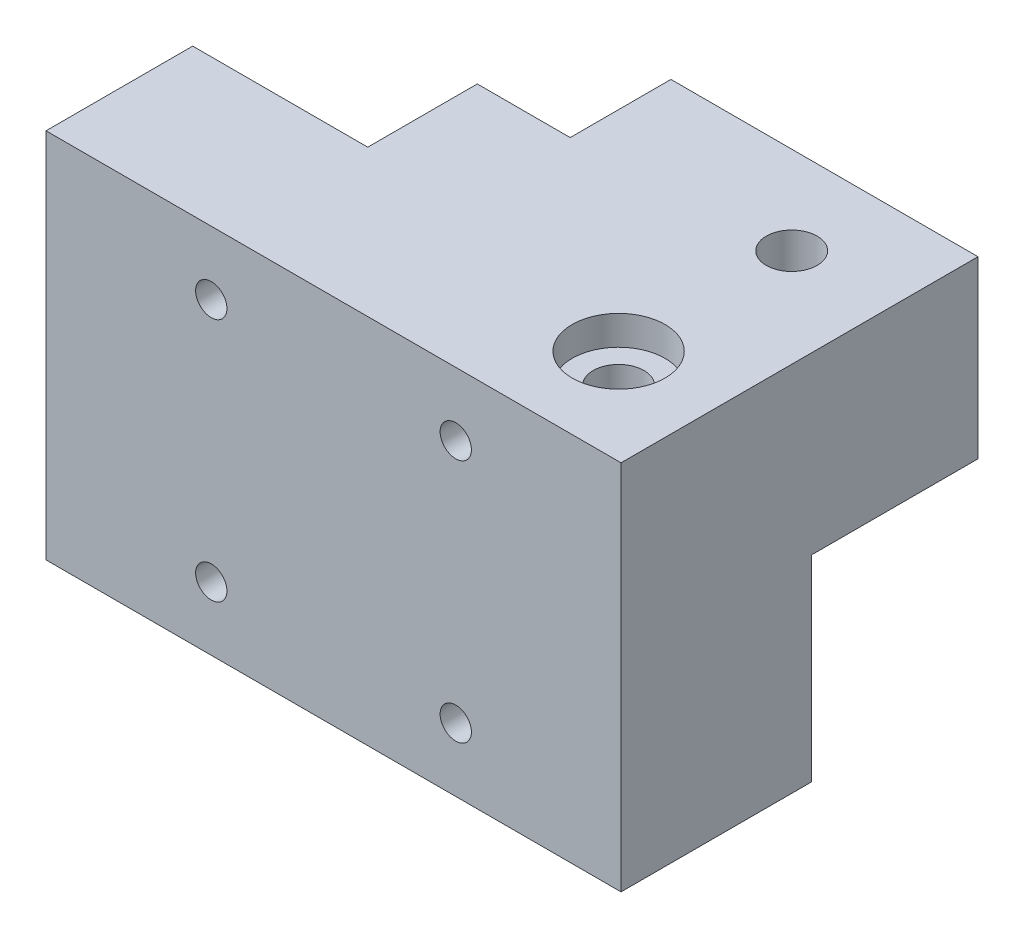
from build123d import *

# Parameters (mm, degrees)
SKETCH_1_W                = 58.8
SKETCH_1_H                = 32
EXTRUDE_1_DEPTH           = 41.5
HOLE_WIZARD_1_D           = 3.2
HOLE_WIZARD_1_CBORE_D     = 6
HOLE_WIZARD_1_CBORE_DEPTH = 32.5
SKETCH_8_R                = 2.6
CUT_EXTRUDE_6_DEPTH       = 33.5
SKETCH_10_W               = 58.8
SKETCH_10_H               = 41.5
EXTRUDE_2_DEPTH           = 3
SKETCH_20_W               = 20
SKETCH_20_H               = 20
SKETCH_20_R               = 3
CUT_EXTRUDE_16_DEPTH      = 22
SKETCH_21_R               = 2.6
CUT_EXTRUDE_17_DEPTH      = 63.093855195
SKETCH_22_W               = 22
SKETCH_22_H               = 20
CUT_EXTRUDE_18_DEPTH      = 0.1
SKETCH_23_W               = 20.1
SKETCH_23_H               = 22
CUT_EXTRUDE_19_DEPTH      = 0.1
SKETCH_24_R               = 2.6
CUT_EXTRUDE_20_DEPTH      = 56.08771962
SKETCH_25_W               = 21.4
SKETCH_25_H               = 23.5
CUT_EXTRUDE_21_DEPTH      = 35
SKETCH_26_W               = 21.4
SKETCH_26_H               = 20
SKETCH_26_R               = 3
CUT_EXTRUDE_22_DEPTH      = 27
SKETCH_27_R               = 3
EXTRUDE_3_DEPTH           = 6
CHAMFER_1_SIZE            = 10
FILLET_1_R                = 5
CUT_EXTRUDE_30_DEPTH      = 5
SKETCH_36_R               = 2.6
CUT_EXTRUDE_31_DEPTH      = 60.855349011
SKETCH_37_R               = 2.6
EXTRUDE_6_DEPTH           = 3
SKETCH_38_W               = 19.040158201
SKETCH_38_H               = 15.764200478
CUT_EXTRUDE_32_DEPTH      = 3
SKETCH_39_W               = 5.883083502
SKETCH_39_H               = 11.158232545
CUT_EXTRUDE_33_DEPTH      = 9
SKETCH_40_W               = 9
SKETCH_40_H               = 11.158232545
CUT_EXTRUDE_34_DEPTH      = 4
CUT_EXTRUDE_35_DEPTH      = 14
CUT_EXTRUDE_37_DEPTH      = 5
CUT_EXTRUDE_38_DEPTH      = 9
SKETCH_44_W               = 27.4
SKETCH_44_H               = 35
SKETCH_44_R               = 3
EXTRUDE_7_DEPTH           = 3
SKETCH_45_R               = 1.5
CUT_EXTRUDE_39_DEPTH      = 6
SKETCH_47_R               = 1.5
CUT_EXTRUDE_41_DEPTH      = 6
SKETCH_48_R               = 2.6
CUT_EXTRUDE_42_DEPTH      = 63.093855195
SKETCH_49_R               = 2.6
EXTRUDE_8_DEPTH           = 35
SKETCH_50_W               = 20.1
SKETCH_50_H               = 17
CUT_EXTRUDE_43_DEPTH      = 7
SKETCH_51_R               = 6.4
EXTRUDE_9_DEPTH           = 5
SKETCH_52_R               = 2.6
EXTRUDE_10_DEPTH          = 6.3
SKETCH_55_W               = 20.1
SKETCH_55_H               = 7
SKETCH_55_R               = 3
EXTRUDE_11_DEPTH          = 17
SKETCH_56_R               = 2.6
CUT_EXTRUDE_46_DEPTH      = 63.093855195
SKETCH_57_W               = 20.1
SKETCH_57_H               = 17
SKETCH_57_R               = 2.6
EXTRUDE_12_DEPTH          = 7.9
SKETCH_58_W               = 20.1
SKETCH_58_H               = 17
CUT_EXTRUDE_47_DEPTH      = 7.9
SKETCH_59_R               = 1.5
EXTRUDE_13_DEPTH          = 6
SKETCH_60_R               = 1.5
EXTRUDE_14_DEPTH          = 11.3
EXTRUDE_15_DEPTH          = 9.5
SKETCH_62_R               = 2.6
CUT_EXTRUDE_48_DEPTH      = 60.855349011
SKETCH_65_R               = 4.5
SKETCH_65_R_2             = 2.6
CUT_EXTRUDE_50_DEPTH      = 5.2
SKETCH_66_R               = 3
CUT_EXTRUDE_51_DEPTH      = 42.633756235
SKETCH_67_R               = 3
CUT_EXTRUDE_52_DEPTH      = 42.633756287
SKETCH_68_R               = 2.6
EXTRUDE_16_DEPTH          = 3
SKETCH_69_R               = 4.75
CUT_EXTRUDE_53_DEPTH      = 3


with BuildPart() as part:
    # 草图1 → 凸台-拉伸1 (new body)
    with BuildSketch(Plane.XY):
        with Locations((-0.739622642, 3.045283019)):
            Rectangle(SKETCH_1_W, SKETCH_1_H)
    extrude(amount=EXTRUDE_1_DEPTH)

    # 孔1 (through all)
    with Locations(Plane(origin=(11.760377358, 15.545283019, 0), x_dir=(-1, 0, 0), z_dir=(0, 0, -1))):
        with Locations((0, 0), (25, 0), (25, -25), (0, -25)):
            CounterBoreHole(HOLE_WIZARD_1_D / 2, HOLE_WIZARD_1_CBORE_D / 2, HOLE_WIZARD_1_CBORE_DEPTH)

    # 草图8 → 切除-拉伸6 (cut)
    with BuildSketch(Plane(origin=(0, 19.045283019, 0), x_dir=(1, 0, 0), z_dir=(0, 1, 0))):
        with Locations(Location((-0.739622642, -31.5, 0), (0, 0, 270))):
            Circle(SKETCH_8_R)
    extrude(amount=-CUT_EXTRUDE_6_DEPTH, mode=Mode.SUBTRACT)

    # 草图10 → 凸台-拉伸2 (add)
    with BuildSketch(Plane.XZ.offset(12.954716981)):
        with Locations((-0.739622642, 20.75)):
            Rectangle(SKETCH_10_W, SKETCH_10_H)
    extrude(amount=EXTRUDE_2_DEPTH)

    # 草图20 → 切除-拉伸16 (cut)
    with BuildSketch(Plane(origin=(0, 0, 0), x_dir=(-1, 0, 0), z_dir=(0, 0, -1))):
        with Locations((-18.660377358, 9.045283019)):
            Rectangle(SKETCH_20_W, SKETCH_20_H)
        with Locations((-11.760377358, 15.545283019)):
            Circle(SKETCH_20_R, mode=Mode.SUBTRACT)
    extrude(amount=-CUT_EXTRUDE_16_DEPTH, mode=Mode.SUBTRACT)

    # 草图21 → 切除-拉伸17 (cut, through all)
    with BuildSketch(Plane(origin=(0, 19.045283019, 0), x_dir=(1, 0, 0), z_dir=(0, 1, 0))):
        with Locations(Location((-0.739622642, -31.5, 0), (0, 0, 270))):
            Circle(SKETCH_21_R)
    extrude(amount=-CUT_EXTRUDE_17_DEPTH, mode=Mode.SUBTRACT)

    # 草图22 → 切除-拉伸18 (cut)
    with BuildSketch(Plane(origin=(8.660377358, 0, 0), x_dir=(0, 0, -1), z_dir=(1, 0, 0))):
        with Locations((-11, 9.045283019)):
            Rectangle(SKETCH_22_W, SKETCH_22_H)
    extrude(amount=-CUT_EXTRUDE_18_DEPTH, mode=Mode.SUBTRACT)

    # 草图23 → 切除-拉伸19 (cut)
    with BuildSketch(Plane(origin=(0, -0.954716981, 0), x_dir=(1, 0, 0), z_dir=(0, 1, 0))):
        with Locations((18.610377358, -11)):
            Rectangle(SKETCH_23_W, SKETCH_23_H)
    extrude(amount=-CUT_EXTRUDE_19_DEPTH, mode=Mode.SUBTRACT)

    # 草图24 → 切除-拉伸20 (cut, through all)
    with BuildSketch(Plane(origin=(0, -1.054716981, 0), x_dir=(1, 0, 0), z_dir=(0, 1, 0))):
        with Locations(Location((18.610377358, -14, 0), (0, 0, 270))):
            Circle(SKETCH_24_R)
    extrude(amount=-CUT_EXTRUDE_20_DEPTH, mode=Mode.SUBTRACT)

    # 草图25 → 切除-拉伸21 (cut)
    with BuildSketch(Plane(origin=(0, 19.045283019, 0), x_dir=(1, 0, 0), z_dir=(0, 1, 0))):
        with Locations((-19.439622642, -17.75)):
            Rectangle(SKETCH_25_W, SKETCH_25_H)
    extrude(amount=-CUT_EXTRUDE_21_DEPTH, mode=Mode.SUBTRACT)

    # 草图26 → 切除-拉伸22 (cut)
    with BuildSketch(Plane(origin=(0, 0, 0), x_dir=(-1, 0, 0), z_dir=(0, 0, -1))):
        with Locations((19.439622642, -5.954716981)):
            Rectangle(SKETCH_26_W, SKETCH_26_H)
        with Locations((13.239622642, -9.454716981)):
            Circle(SKETCH_26_R, mode=Mode.SUBTRACT)
    extrude(amount=-CUT_EXTRUDE_22_DEPTH, mode=Mode.SUBTRACT)

    # 草图27 → 凸台-拉伸3 (add, through all)
    with BuildSketch(Plane.XY.offset(6)):
        with Locations(Location((-13.239622642, 15.545283019, 0), (0, 0, 180))):
            Circle(SKETCH_27_R)
    extrude(amount=-EXTRUDE_3_DEPTH)

    # 倒角1
    chamfer_1_edges = [part.edges().sort_by_distance(p)[0] for p in [
        (-30.139622642, 19.045283019, 3),
    ]]
    chamfer(chamfer_1_edges, length=CHAMFER_1_SIZE)

    # 圆角1
    fillet_1_edges = [part.edges().sort_by_distance(p)[0] for p in [
        (-30.139622642, 9.045283019, 3),
        (-20.139622642, 19.045283019, 3),
    ]]
    fillet(fillet_1_edges, radius=FILLET_1_R)

    # 草图35 → 切除-拉伸30 (cut)
    with BuildSketch(Plane(origin=(0, 0, 0), x_dir=(-1, 0, 0), z_dir=(0, 0, -1))):
        with BuildLine():
            Line((30.139622642, 4.045283019), (30.139622642, 6.974215207))
            ThreePointArc((30.139622642, 6.974215207), (29.759020304, 8.887632369), (28.675156547, 10.509749113))
            Line((28.675156547, 10.509749113), (21.604088736, 17.580816925))
            ThreePointArc((21.604088736, 17.580816925), (19.981971991, 18.664680681), (18.06855483, 19.045283019))
            Line((18.06855483, 19.045283019), (-8.560377358, 19.045283019))
            Line((-8.560377358, 19.045283019), (-8.560377358, -1.054716981))
            Line((-8.560377358, -1.054716981), (-28.660377358, -1.054716981))
            Line((-28.660377358, -1.054716981), (-28.660377358, -15.954716981))
            Line((-28.660377358, -15.954716981), (8.739622642, -15.954716981))
            Line((8.739622642, -15.954716981), (8.739622642, 4.045283019))
            Line((8.739622642, 4.045283019), (30.139622642, 4.045283019))
        make_face()
    extrude(amount=-CUT_EXTRUDE_30_DEPTH, mode=Mode.SUBTRACT)

    # 草图36 → 切除-拉伸31 (cut, through all)
    with BuildSketch(Plane(origin=(8.560377358, 0, 0), x_dir=(0, 0, -1), z_dir=(1, 0, 0))):
        with Locations(Location((-13.5, 8.995283019, 0), (0, 0, 90))):
            Circle(SKETCH_36_R)
    extrude(amount=-CUT_EXTRUDE_31_DEPTH, mode=Mode.SUBTRACT)

    # 草图37 → 凸台-拉伸6 (add)
    with BuildSketch(Plane.ZY.offset(8.739622642)):
        Polygon((5, 4.045283019), (5, -15.954716981), (29.5, -15.954716981), (29.5, 19.045283019), (6, 19.045283019), (6, 4.045283019), align=None)
        with Locations(Location((13.5, 8.995283019, 0), (0, 0, 90))):
            Circle(SKETCH_37_R, mode=Mode.SUBTRACT)
    extrude(amount=EXTRUDE_6_DEPTH)

    # 草图38 → 切除-拉伸32 (cut)
    with BuildSketch(Plane(origin=(0, 0, 5), x_dir=(-1, 0, 0), z_dir=(0, 0, -1))):
        with Locations((21.259701742, 11.927383258)):
            Rectangle(SKETCH_38_W, SKETCH_38_H)
    extrude(amount=-CUT_EXTRUDE_32_DEPTH, mode=Mode.SUBTRACT)

    # 草图39 → 切除-拉伸33 (cut)
    with BuildSketch(Plane.ZY.offset(11.739622642)):
        with Locations((7.941541751, 13.466166747)):
            Rectangle(SKETCH_39_W, SKETCH_39_H)
    extrude(amount=-CUT_EXTRUDE_33_DEPTH, mode=Mode.SUBTRACT)

    # 草图40 → 切除-拉伸34 (cut)
    with BuildSketch(Plane(origin=(0, 0, 10.883083502), x_dir=(-1, 0, 0), z_dir=(0, 0, -1))):
        with Locations((7.239622642, 13.466166747)):
            Rectangle(SKETCH_40_W, SKETCH_40_H)
    extrude(amount=-CUT_EXTRUDE_34_DEPTH, mode=Mode.SUBTRACT)

    # 草图41 → 切除-拉伸35 (cut)
    with BuildSketch(Plane.ZY.offset(11.739622642)):
        with BuildLine():
            ThreePointArc((16.1, 8.995283019), (15.338477631, 7.156805388), (13.5, 6.395283019))
            ThreePointArc((13.5, 6.395283019), (12.107413309, 6.799673238), (11.148017724, 7.887050474))
            Line((11.148017724, 7.887050474), (7.196681777, 7.887050474))
            ThreePointArc((7.196681777, 7.887050474), (17.925328842, 4.371814122), (14.883083502, 15.244049299))
            Line((14.883083502, 15.244049299), (14.883083502, 11.196891528))
            ThreePointArc((14.883083502, 11.196891528), (15.775523797, 10.253055434), (16.1, 8.995283019))
        make_face()
    extrude(amount=-CUT_EXTRUDE_35_DEPTH, mode=Mode.SUBTRACT)

    # 草图42 → 切除-拉伸37 (cut)
    with BuildSketch(Plane.ZY.offset(2.739622642)):
        with BuildLine():
            ThreePointArc((14.883083502, 15.244049299), (9.074671158, 13.618751916), (7.196681777, 7.887050474))
            Line((7.196681777, 7.887050474), (11.148017724, 7.887050474))
            ThreePointArc((11.148017724, 7.887050474), (11.775629634, 10.941188166), (14.883083502, 11.196891528))
            Line((14.883083502, 11.196891528), (14.883083502, 15.244049299))
        make_face()
    extrude(amount=-CUT_EXTRUDE_37_DEPTH, mode=Mode.SUBTRACT)

    # 草图43 → 切除-拉伸38 (cut)
    with BuildSketch(Plane.ZY.offset(11.739622642)):
        with BuildLine():
            Line((14.883083502, 19.045283019), (14.883083502, 15.244049299))
            ThreePointArc((14.883083502, 15.244049299), (17.925328842, 4.371814122), (7.196681777, 7.887050474))
            Line((7.196681777, 7.887050474), (5, 7.887050474))
            Line((5, 7.887050474), (5, -15.954716981))
            Line((5, -15.954716981), (29.5, -15.954716981))
            Line((29.5, -15.954716981), (29.5, -12.052793192))
            Line((29.5, -12.052793192), (29.5, -6.85664077))
            Line((29.5, -6.85664077), (29.5, 12.947206808))
            Line((29.5, 12.947206808), (29.5, 18.14335923))
            Line((29.5, 18.14335923), (29.5, 19.045283019))
            Line((29.5, 19.045283019), (14.883083502, 19.045283019))
        make_face()
    extrude(amount=-CUT_EXTRUDE_38_DEPTH, mode=Mode.SUBTRACT)

    # 草图44 → 凸台-拉伸7 (add)
    with BuildSketch(Plane(origin=(0, 0, 29.5), x_dir=(-1, 0, 0), z_dir=(0, 0, -1))):
        with Locations((16.439622642, 1.545283019)):
            Rectangle(SKETCH_44_W, SKETCH_44_H)
        with Locations((13.239622642, 15.545283019)):
            Circle(SKETCH_44_R, mode=Mode.SUBTRACT)
        with Locations((13.239622642, -9.454716981)):
            Circle(SKETCH_44_R, mode=Mode.SUBTRACT)
    extrude(amount=EXTRUDE_7_DEPTH)

    # 草图45 → 切除-拉伸39 (cut)
    with BuildSketch(Plane.ZY.offset(2.739622642)):
        with Locations((22, 12.225283019)):
            Circle(SKETCH_45_R)
    extrude(amount=-CUT_EXTRUDE_39_DEPTH, mode=Mode.SUBTRACT)

    # 草图47 → 切除-拉伸41 (cut)
    with BuildSketch(Plane.ZY.offset(2.739622642)):
        with Locations((15.75, -7.954716981)):
            Circle(SKETCH_47_R)
    extrude(amount=-CUT_EXTRUDE_41_DEPTH, mode=Mode.SUBTRACT)

    # 草图48 → 切除-拉伸42 (cut, through all)
    with BuildSketch(Plane(origin=(0, 19.045283019, 0), x_dir=(1, 0, 0), z_dir=(0, 1, 0))):
        with Locations(Location((18.660377358, -31.75, 0), (0, 0, 270))):
            Circle(SKETCH_48_R)
    extrude(amount=-CUT_EXTRUDE_42_DEPTH, mode=Mode.SUBTRACT)

    # 草图49 → 凸台-拉伸8 (add, through all)
    with BuildSketch(Plane(origin=(0, 19.045283019, 0), x_dir=(1, 0, 0), z_dir=(0, 1, 0))):
        with Locations((-0.739622642, -31.5)):
            Circle(SKETCH_49_R)
    extrude(amount=-EXTRUDE_8_DEPTH)

    # 草图50 → 切除-拉伸43 (cut)
    with BuildSketch(Plane(origin=(0, -1.054716981, 0), x_dir=(1, 0, 0), z_dir=(0, 1, 0))):
        with Locations((18.610377358, -13.5)):
            Rectangle(SKETCH_50_W, SKETCH_50_H)
    extrude(amount=-CUT_EXTRUDE_43_DEPTH, mode=Mode.SUBTRACT)

    # 草图51 → 凸台-拉伸9 (add)
    with BuildSketch(Plane.ZY.offset(-2.260377358)):
        with Locations((13.5, 8.995283019)):
            Circle(SKETCH_51_R)
    extrude(amount=EXTRUDE_9_DEPTH)

    # 草图52 → 凸台-拉伸10 (add)
    with BuildSketch(Plane(origin=(2.260377358, 0, 0), x_dir=(0, 0, -1), z_dir=(1, 0, 0))):
        with Locations((-13.5, 8.995283019)):
            Circle(SKETCH_52_R)
    extrude(amount=EXTRUDE_10_DEPTH)

    # 草图55 → 凸台-拉伸11 (add)
    with BuildSketch(Plane(origin=(0, 0, 22), x_dir=(-1, 0, 0), z_dir=(0, 0, -1))):
        with Locations((-18.610377358, 15.545283019)):
            Rectangle(SKETCH_55_W, SKETCH_55_H)
        with Locations((-11.760377358, 15.545283019)):
            Circle(SKETCH_55_R, mode=Mode.SUBTRACT)
    extrude(amount=EXTRUDE_11_DEPTH)

    # 草图56 → 切除-拉伸46 (cut, through all)
    with BuildSketch(Plane(origin=(0, 19.045283019, 0), x_dir=(1, 0, 0), z_dir=(0, 1, 0))):
        with Locations(Location((18.610377358, -14, 0), (0, 0, 270))):
            Circle(SKETCH_56_R)
    extrude(amount=-CUT_EXTRUDE_46_DEPTH, mode=Mode.SUBTRACT)

    # 草图57 → 凸台-拉伸12 (add)
    with BuildSketch(Plane.XZ.offset(-12.045283019)):
        with Locations((18.610377358, 13.5)):
            Rectangle(SKETCH_57_W, SKETCH_57_H)
        with Locations(Location((18.610377358, 14, 0), (0, 0, 90))):
            Circle(SKETCH_57_R, mode=Mode.SUBTRACT)
    extrude(amount=EXTRUDE_12_DEPTH)

    # 草图58 → 切除-拉伸47 (cut)
    with BuildSketch(Plane(origin=(0, -8.054716981, 0), x_dir=(1, 0, 0), z_dir=(0, 1, 0))):
        with Locations((18.610377358, -13.5)):
            Rectangle(SKETCH_58_W, SKETCH_58_H)
    extrude(amount=-CUT_EXTRUDE_47_DEPTH, mode=Mode.SUBTRACT)

    # 草图59 → 凸台-拉伸13 (add)
    with BuildSketch(Plane.ZY.offset(-3.260377358)):
        with Locations((15.75, -7.954716981)):
            Circle(SKETCH_59_R)
    extrude(amount=EXTRUDE_13_DEPTH)

    # 草图60 → 凸台-拉伸14 (add)
    with BuildSketch(Plane(origin=(8.560377358, 0, 0), x_dir=(0, 0, -1), z_dir=(1, 0, 0))):
        with Locations((-22, 12.225283019)):
            Circle(SKETCH_60_R)
    extrude(amount=-EXTRUDE_14_DEPTH)

    # 草图61 → 凸台-拉伸15 (add)
    with BuildSketch(Plane.ZY.offset(2.739622642)):
        Polygon((5, 3.545283019), (15.3, 3.545283019), (15.3, 19.045283019), (26.5, 19.045283019), (26.5, -15.954716981), (5, -15.954716981), align=None)
    extrude(amount=EXTRUDE_15_DEPTH)

    # 草图62 → 切除-拉伸48 (cut, through all)
    with BuildSketch(Plane(origin=(8.560377358, 0, 0), x_dir=(0, 0, -1), z_dir=(1, 0, 0))):
        with Locations(Location((-13.5, -5.854716981, 0), (0, 0, 90))):
            Circle(SKETCH_62_R)
    extrude(amount=-CUT_EXTRUDE_48_DEPTH, mode=Mode.SUBTRACT)

    # 草图65 → 切除-拉伸50 (cut)
    with BuildSketch(Plane.ZY.offset(12.239622642)):
        with Locations((13.5, -5.854716981)):
            Circle(SKETCH_65_R)
        with Locations(Location((13.5, -5.854716981, 0), (0, 0, 90))):
            Circle(SKETCH_65_R_2, mode=Mode.SUBTRACT)
    extrude(amount=-CUT_EXTRUDE_50_DEPTH, mode=Mode.SUBTRACT)

    # 草图66 → 切除-拉伸51 (cut, through all)
    with BuildSketch(Plane(origin=(0, 0, 26.5), x_dir=(-1, 0, 0), z_dir=(0, 0, -1))):
        with Locations((13.239622642, -9.454716981)):
            Circle(SKETCH_66_R)
    extrude(amount=CUT_EXTRUDE_51_DEPTH, mode=Mode.SUBTRACT)

    # 草图67 → 切除-拉伸52 (cut, through all)
    with BuildSketch(Plane(origin=(0, 0, 26.5), x_dir=(-1, 0, 0), z_dir=(0, 0, -1))):
        with Locations((13.239622642, 15.545283019)):
            Circle(SKETCH_67_R)
    extrude(amount=CUT_EXTRUDE_52_DEPTH, mode=Mode.SUBTRACT)

    # 草图68 → 凸台-拉伸16 (add)
    with BuildSketch(Plane(origin=(0, 19.045283019, 0), x_dir=(1, 0, 0), z_dir=(0, 1, 0))):
        Polygon((-2.739622642, -5), (-2.739622642, -15.3), (-12.239622642, -15.3), (-12.239622642, -26.5), (-30.139622642, -26.5), (-30.139622642, -41.5), (28.660377358, -41.5), (28.660377358, -5), align=None)
        with Locations(Location((18.610377358, -14, 0), (0, 0, 270))):
            Circle(SKETCH_68_R, mode=Mode.SUBTRACT)
        with Locations(Location((18.660377358, -31.75, 0), (0, 0, 270))):
            Circle(SKETCH_68_R, mode=Mode.SUBTRACT)
    extrude(amount=EXTRUDE_16_DEPTH)

    # 草图69 → 切除-拉伸53 (cut)
    with BuildSketch(Plane(origin=(0, 22.045283019, 0), x_dir=(1, 0, 0), z_dir=(0, 1, 0))):
        with Locations(Location((18.660377358, -31.75, 0), (0, 0, 270))):
            Circle(SKETCH_69_R)
    extrude(amount=-CUT_EXTRUDE_53_DEPTH, mode=Mode.SUBTRACT)


solid = part.part
